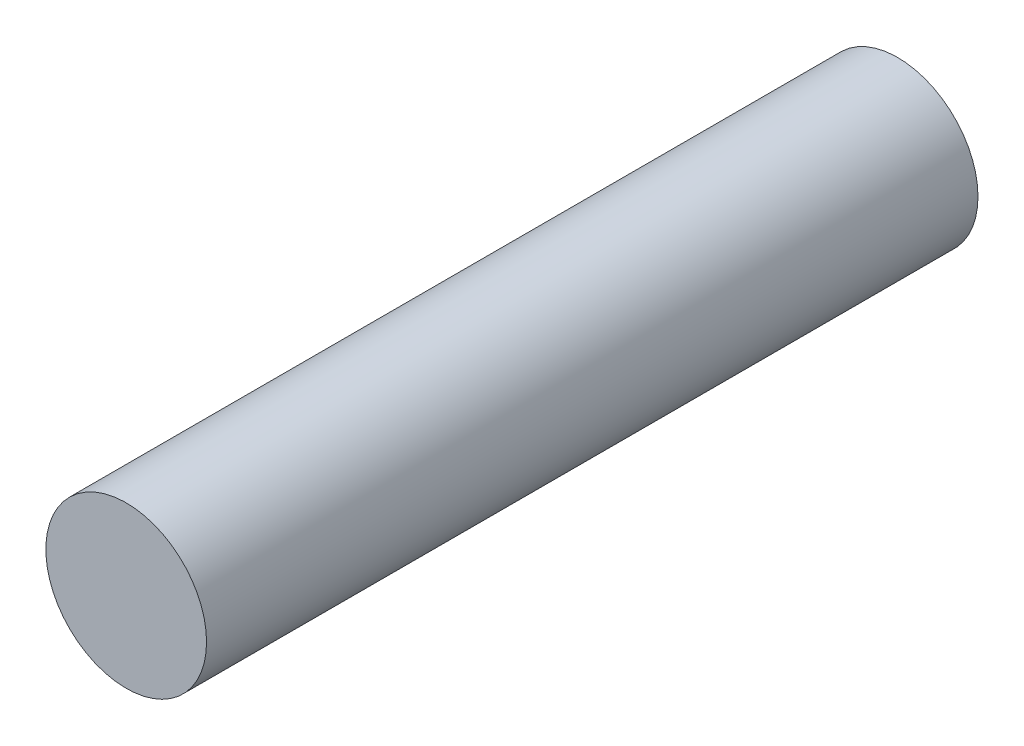
from build123d import *

# Parameters (mm, degrees)
SKETCH1_R           = 7.5
BOSS_EXTRUDE1_DEPTH = 36


with BuildPart() as part:
    # Sketch1 → Boss-Extrude1 (new body, symmetric)
    with BuildSketch(Plane.XY):
        Circle(SKETCH1_R)
    extrude(amount=BOSS_EXTRUDE1_DEPTH, both=True)


solid = part.part
